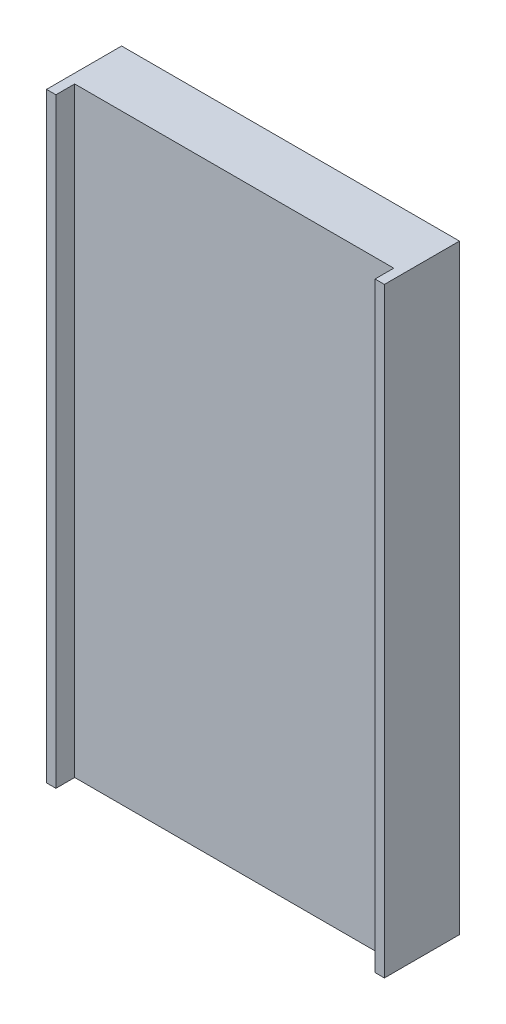
from build123d import *

# Parameters (mm, degrees)
SKETCH1_W           = 4.25
SKETCH1_H           = 8
BOSS_EXTRUDE1_DEPTH = 0.75
SKETCH1_3_W         = 0.125
SKETCH1_3_H         = 8
BOSS_EXTRUDE2_DEPTH = 1


with BuildPart() as part:
    # Sketch1 → Boss-Extrude1 (new body)
    with BuildSketch(Plane.XY):
        Rectangle(SKETCH1_W, SKETCH1_H)
    extrude(amount=BOSS_EXTRUDE1_DEPTH)

    # Sketch1_3 → Boss-Extrude2 (add)
    with BuildSketch(Plane.XY):
        with Locations((-2.1875, 0)):
            Rectangle(SKETCH1_3_W, SKETCH1_3_H)
        with Locations((2.1875, 0)):
            Rectangle(SKETCH1_3_W, SKETCH1_3_H)
    extrude(amount=BOSS_EXTRUDE2_DEPTH)


solid = part.part
